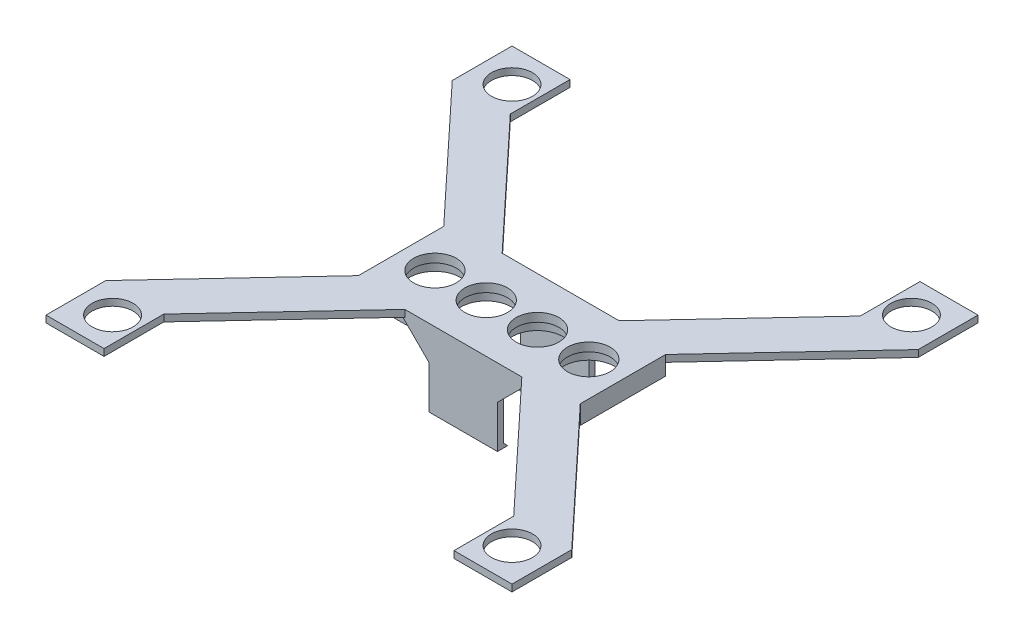
from build123d import *

# Parameters (mm, degrees)
SKICA1_W                 = 26
SKICA1_H                 = 1
P_IDAT_VYSUNUT_M1_DEPTH  = 10
SKICA2_R                 = 2.5
ODEBRAT_VYSUNUT_M1_DEPTH = 1
SKICA3_R                 = 2.4
P_IDAT_VYSUNUT_M2_DEPTH  = 0.8
SKICA4_W                 = 26
SKICA4_H                 = 10
SKICA4_R                 = 3
P_IDAT_VYSUNUT_M3_DEPTH  = 1.2
SKICA6_W                 = 8
SKICA6_H                 = 0.7
P_IDAT_VYSUNUT_M5_DEPTH  = 9
P_IDAT_VYSUNUT_M6_DEPTH  = 8
P_IDAT_VYSUNUT_M8_DEPTH  = 0.7
P_IDAT_VYSUNUT_M9_DEPTH  = 0.7


with BuildPart() as part:
    # Skica1 → Přidat vysunutím1 (new body)
    with BuildSketch(Plane.XY):
        with Locations((-39.156744291, -7.214704976)):
            Rectangle(SKICA1_W, SKICA1_H)
    extrude(amount=P_IDAT_VYSUNUT_M1_DEPTH)

    # Skica2 → Odebrat vysunutím1 (cut)
    with BuildSketch(Plane(origin=(0, -7.714704976, 0), x_dir=(-1, 0, 0), z_dir=(0, -1, 0))):
        with Locations((48.186744291, -5)):
            Circle(SKICA2_R)
        with Locations((42.176744291, -5)):
            Circle(SKICA2_R)
        with Locations((36.166744291, -5)):
            Circle(SKICA2_R)
        with Locations((30.156744291, -5)):
            Circle(SKICA2_R)
    extrude(amount=-ODEBRAT_VYSUNUT_M1_DEPTH, mode=Mode.SUBTRACT)

    # Skica3 → Přidat vysunutím2 (add)
    with BuildSketch(Plane(origin=(0, -6.714704976, 0), x_dir=(1, 0, 0), z_dir=(0, 1, 0))):
        Polygon((-32.956744291, 0), (-18.656744291, 15.3), (-18.656744291, 22.3), (-11.856744291, 22.3), (-11.856744291, 15.3), (-26.156744291, 0), align=None)
        with Locations((-15.756744291, 18.4)):
            Circle(SKICA3_R, mode=Mode.SUBTRACT)
        Polygon((-52.156744291, 0), (-45.356744291, 0), (-59.656744291, 15.3), (-59.656744291, 22.3), (-66.456744291, 22.3), (-66.456744291, 15.3), align=None)
        with Locations((-62.556744291, 18.4)):
            Circle(SKICA3_R, mode=Mode.SUBTRACT)
        Polygon((-45.356744291, -10), (-59.656744291, -25.3), (-59.656744291, -32.3), (-66.456744291, -32.3), (-66.456744291, -25.3), (-52.156744291, -10), align=None)
        with Locations((-62.556744291, -28.4)):
            Circle(SKICA3_R, mode=Mode.SUBTRACT)
        Polygon((-26.156744291, -10), (-32.956744291, -10), (-18.656744291, -25.3), (-18.656744291, -32.3), (-11.856744291, -32.3), (-11.856744291, -25.3), align=None)
        with Locations((-15.756744291, -28.4)):
            Circle(SKICA3_R, mode=Mode.SUBTRACT)
    extrude(amount=-P_IDAT_VYSUNUT_M2_DEPTH)

    # Skica4 → Přidat vysunutím3 (add)
    with BuildSketch(Plane(origin=(0, -7.714704976, 0), x_dir=(-1, 0, 0), z_dir=(0, -1, 0))):
        with Locations((39.156744291, -5)):
            Rectangle(SKICA4_W, SKICA4_H)
        with Locations((48.186744291, -5)):
            Circle(SKICA4_R, mode=Mode.SUBTRACT)
        with Locations((42.176744291, -5)):
            Circle(SKICA4_R, mode=Mode.SUBTRACT)
        with Locations((36.166744291, -5)):
            Circle(SKICA4_R, mode=Mode.SUBTRACT)
        with Locations((30.156744291, -5)):
            Circle(SKICA4_R, mode=Mode.SUBTRACT)
    extrude(amount=P_IDAT_VYSUNUT_M3_DEPTH)

    # Skica6 → Přidat vysunutím5 (add)
    with BuildSketch(Plane(origin=(0, -6.714704976, 0), x_dir=(1, 0, 0), z_dir=(0, 1, 0))):
        with Locations((-39.156744291, 0.35)):
            Rectangle(SKICA6_W, SKICA6_H)
        with Locations((-39.156744291, -10.35)):
            Rectangle(SKICA6_W, SKICA6_H)
    extrude(amount=-P_IDAT_VYSUNUT_M5_DEPTH)

    # Skica7 → Přidat vysunutím6 (add)
    with BuildSketch(Plane(origin=(-35.156744291, 0, 0), x_dir=(0, 0, -1), z_dir=(1, 0, 0))):
        Polygon((-10, -15.714704976), (-9.5, -15.714704976), (-10, -15.214704976), align=None)
        Polygon((0, -15.714704976), (0, -15.214704976), (-0.5, -15.714704976), align=None)
    extrude(amount=-P_IDAT_VYSUNUT_M6_DEPTH)

    # Skica8 → Přidat vysunutím8 (add)
    with BuildSketch(Plane(origin=(0, 0, 0), x_dir=(-1, 0, 0), z_dir=(0, 0, -1))):
        Polygon((43.156744291, -6.714704976), (43.156744291, -10.714704976), (47.156744291, -6.714704976), align=None)
        Polygon((35.156744291, -10.714704976), (35.156744291, -6.714704976), (31.156744291, -6.714704976), align=None)
    extrude(amount=P_IDAT_VYSUNUT_M8_DEPTH)

    # Skica9 → Přidat vysunutím9 (add)
    with BuildSketch(Plane.XY.offset(10)):
        Polygon((-43.156744291, -6.714704976), (-47.156744291, -6.714704976), (-43.156744291, -10.714704976), align=None)
        Polygon((-35.156744291, -6.714704976), (-35.156744291, -10.714704976), (-31.156744291, -6.714704976), align=None)
    extrude(amount=P_IDAT_VYSUNUT_M9_DEPTH)


solid = part.part
